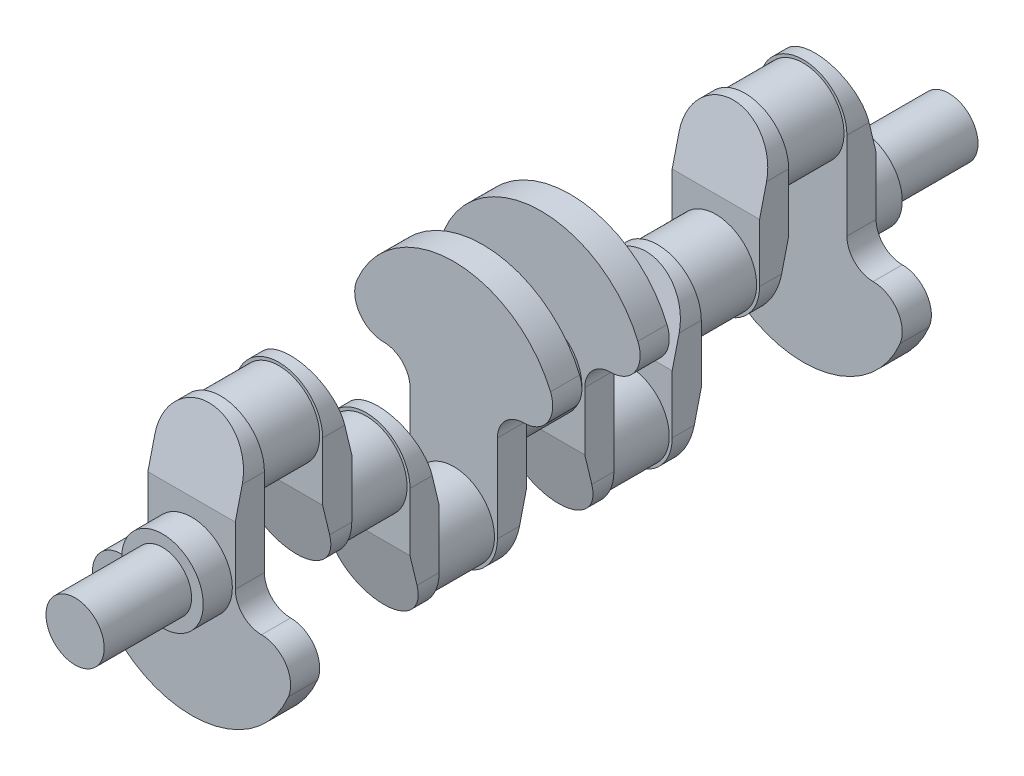
from build123d import *

# Parameters (mm, degrees)
BOSS_EXTRUDE1_DEPTH  = 50
CUT_EXTRUDE1_DEPTH   = 246
SKETCH6_R            = 70
BOSS_EXTRUDE2_DEPTH  = 100
BOSS_EXTRUDE3_DEPTH  = 50
SKETCH8_R            = 70
BOSS_EXTRUDE4_DEPTH  = 100
BOSS_EXTRUDE5_DEPTH  = 50
SKETCH10_R           = 70
BOSS_EXTRUDE6_DEPTH  = 100
BOSS_EXTRUDE7_DEPTH  = 50
SKETCH12_R           = 70
BOSS_EXTRUDE8_DEPTH  = 50
SKETCH13_R           = 70
BOSS_EXTRUDE9_DEPTH  = 50
SKETCH14_R           = 50
BOSS_EXTRUDE11_DEPTH = 150
CUT_EXTRUDE2_DEPTH   = 246


with BuildPart() as part:
    # Sketch1 → Boss-Extrude1 (new body)
    with BuildSketch(Plane.XY):
        with BuildLine():
            Line((-75, 120), (-75, -30))
            ThreePointArc((-75, -30), (-88.180194847, -61.819805153), (-120, -75))
            ThreePointArc((-120, -75), (-161.602514717, -97.264990189), (-166.153846154, -144.230769231))
            ThreePointArc((-166.153846154, -144.230769231), (0, -255), (166.153846154, -144.230769231))
            ThreePointArc((166.153846154, -144.230769231), (161.602514717, -97.264990189), (120, -75))
            ThreePointArc((120, -75), (88.180194847, -61.819805153), (75, -30))
            Line((75, -30), (75, 120))
            ThreePointArc((75, 120), (0, 195), (-75, 120))
        make_face()
    extrude(amount=BOSS_EXTRUDE1_DEPTH)

    # Sketch5 → Cut-Extrude1 (cut, through all)
    with BuildSketch(Plane(origin=(75, 0, 0), x_dir=(0, 0, -1), z_dir=(1, 0, 0))):
        Polygon((-50, 70), (-50, 195), (-20, 195), align=None)
    extrude(amount=-CUT_EXTRUDE1_DEPTH, mode=Mode.SUBTRACT)

    # Sketch6 → Boss-Extrude2 (add)
    with BuildSketch(Plane(origin=(0, 0, 0), x_dir=(-1, 0, 0), z_dir=(0, 0, -1))):
        with Locations((0, 120)):
            Circle(SKETCH6_R)
    extrude(amount=BOSS_EXTRUDE2_DEPTH)

    # Sketch7 → Boss-Extrude3 (add)
    with BuildSketch(Plane(origin=(0, 0, -100), x_dir=(-1, 0, 0), z_dir=(0, 0, -1))):
        with BuildLine():
            Line((75, 120), (75, -30))
            ThreePointArc((75, -30), (0, -105), (-75, -30))
            Line((-75, -30), (-75, 120))
            ThreePointArc((-75, 120), (0, 195), (75, 120))
        make_face()
    extrude(amount=BOSS_EXTRUDE3_DEPTH)

    # Sketch8 → Boss-Extrude4 (add)
    with BuildSketch(Plane(origin=(0, 0, -150), x_dir=(-1, 0, 0), z_dir=(0, 0, -1))):
        with Locations((0, -30)):
            Circle(SKETCH8_R)
    extrude(amount=BOSS_EXTRUDE4_DEPTH)

    # Sketch9 → Boss-Extrude5 (add)
    with BuildSketch(Plane(origin=(0, 0, -250), x_dir=(-1, 0, 0), z_dir=(0, 0, -1))):
        with BuildLine():
            Line((75, -30), (75, -180))
            ThreePointArc((75, -180), (0, -255), (-75, -180))
            Line((-75, -180), (-75, -30))
            ThreePointArc((-75, -30), (0, 45), (75, -30))
        make_face()
    extrude(amount=BOSS_EXTRUDE5_DEPTH)

    # Sketch10 → Boss-Extrude6 (add)
    with BuildSketch(Plane(origin=(0, 0, -300), x_dir=(-1, 0, 0), z_dir=(0, 0, -1))):
        with Locations((0, -180)):
            Circle(SKETCH10_R)
    extrude(amount=BOSS_EXTRUDE6_DEPTH)

    # Sketch11 → Boss-Extrude7 (add)
    with BuildSketch(Plane(origin=(0, 0, -400), x_dir=(-1, 0, 0), z_dir=(0, 0, -1))):
        with BuildLine():
            Line((75, -180), (75, -30))
            ThreePointArc((75, -30), (88.180194847, 1.819805153), (120, 15))
            ThreePointArc((120, 15), (161.602514717, 37.264990189), (166.153846154, 84.230769231))
            ThreePointArc((166.153846154, 84.230769231), (0, 195), (-166.153846154, 84.230769231))
            ThreePointArc((-166.153846154, 84.230769231), (-161.602514717, 37.264990189), (-120, 15))
            ThreePointArc((-120, 15), (-88.180194847, 1.819805153), (-75, -30))
            Line((-75, -30), (-75, -180))
            ThreePointArc((-75, -180), (0, -255), (75, -180))
        make_face()
    extrude(amount=BOSS_EXTRUDE7_DEPTH)

    # Sketch12 → Boss-Extrude8 (add)
    with BuildSketch(Plane(origin=(0, 0, -450), x_dir=(-1, 0, 0), z_dir=(0, 0, -1))):
        with Locations((0, -30)):
            Circle(SKETCH12_R)
    extrude(amount=BOSS_EXTRUDE8_DEPTH)

    # Sketch13 → Boss-Extrude9 (add)
    with BuildSketch(Plane.XY.offset(50)):
        with Locations((0, -30)):
            Circle(SKETCH13_R)
    extrude(amount=BOSS_EXTRUDE9_DEPTH)

    # Sketch14 → Boss-Extrude11 (add)
    with BuildSketch(Plane.XY.offset(100)):
        with Locations((0, -30)):
            Circle(SKETCH14_R)
    extrude(amount=BOSS_EXTRUDE11_DEPTH)

    # Sketch15 → Cut-Extrude2 (cut, through all)
    with BuildSketch(Plane(origin=(75, 0, 0), x_dir=(0, 0, -1), z_dir=(1, 0, 0))):
        Polygon((100, 20), (100, -105), (130, -105), align=None)
        Polygon((150, 70), (150, 195), (120, 195), align=None)
        Polygon((300, -80), (300, 45), (270, 45), align=None)
        Polygon((250, -130), (250, -255), (280, -255), align=None)
        Polygon((450, -130), (450, -255), (420, -255), align=None)
    extrude(amount=-CUT_EXTRUDE2_DEPTH, mode=Mode.SUBTRACT)

    # Mirror2: part across plane


with BuildPart() as part_1:
    add(part.part)
    add(part.part.mirror(Plane(origin=(0, -30, -500), x_dir=(1, 0, 0), z_dir=(0, 0, -1))))


solid = part_1.part
